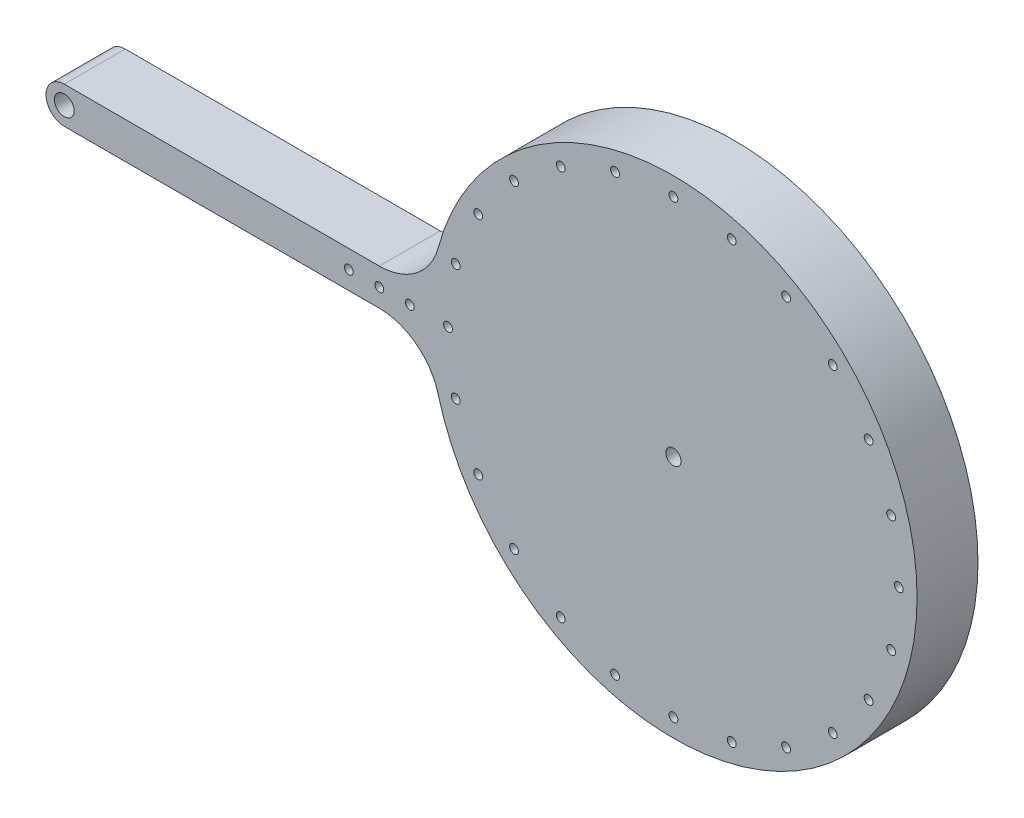
from build123d import *

# Parameters (mm, degrees)
SKETCH1_R           = 1.45
SKETCH1_R_2         = 1.450000001
SKETCH1_R_3         = 3.250000001
SKETCH1_R_4         = 2.5
BOSS_EXTRUDE2_DEPTH = 20


with BuildPart() as part:
    # Sketch1 → Boss-Extrude2 (new body)
    with BuildSketch(Plane.XY):
        with BuildLine():
            Line((-155.352886895, 10.211716756), (-51.913748531, 10.211716756))
            ThreePointArc((-51.913748531, 10.211716756), (-39.74822347, 6.086224622), (-32.601576204, -4.588283244))
            ThreePointArc((-32.601576204, -4.588283244), (53.610301025, -63.284580406), (124.587919611, 13.13479368))
            ThreePointArc((124.587919611, 13.13479368), (56.661218885, 95.304455124), (-32.601576204, 37.011716756))
            ThreePointArc((-32.601576204, 37.011716756), (-39.74822347, 26.33720889), (-51.913748531, 22.211716756))
            Line((-51.913748531, 22.211716756), (-155.352886895, 22.211716756))
            ThreePointArc((-155.352886895, 22.211716756), (-161.352886895, 16.211716756), (-155.352886895, 10.211716756))
        make_face()
        with Locations((-19.438766773, -20.788283244)):
            Circle(SKETCH1_R, mode=Mode.SUBTRACT)
        with Locations((-26.831398039, -2.940892579)):
            Circle(SKETCH1_R_2, mode=Mode.SUBTRACT)
        with Locations((-155.352886895, 16.211716756)):
            Circle(SKETCH1_R_3, mode=Mode.SUBTRACT)
        with Locations((-26.831398039, 35.364326096)):
            Circle(SKETCH1_R_2, mode=Mode.SUBTRACT)
        with Locations((-19.438766774, 53.211716759)):
            Circle(SKETCH1_R_2, mode=Mode.SUBTRACT)
        with Locations((-29.352886893, 16.211716758)):
            Circle(SKETCH1_R_2, mode=Mode.SUBTRACT)
        with Locations((-51.913748531, 16.211716758)):
            Circle(SKETCH1_R, mode=Mode.SUBTRACT)
        with Locations((-41.913748531, 16.211716758)):
            Circle(SKETCH1_R, mode=Mode.SUBTRACT)
        with Locations((-61.913748531, 16.211716758)):
            Circle(SKETCH1_R, mode=Mode.SUBTRACT)
        with Locations((116.125624253, -2.940892579)):
            Circle(SKETCH1_R_2, mode=Mode.SUBTRACT)
        with Locations((108.732992988, -20.788283242)):
            Circle(SKETCH1_R_2, mode=Mode.SUBTRACT)
        with Locations((96.973014915, -36.114185049)):
            Circle(SKETCH1_R_2, mode=Mode.SUBTRACT)
        with Locations((81.647113106, -47.874163121)):
            Circle(SKETCH1_R_2, mode=Mode.SUBTRACT)
        with Locations((63.799722443, -55.266794386)):
            Circle(SKETCH1_R_2, mode=Mode.SUBTRACT)
        with Locations((44.647113106, -57.788283242)):
            Circle(SKETCH1_R_2, mode=Mode.SUBTRACT)
        with Locations((25.494503768, -55.266794386)):
            Circle(SKETCH1_R_2, mode=Mode.SUBTRACT)
        with Locations((7.647113108, -47.874163121)):
            Circle(SKETCH1_R_2, mode=Mode.SUBTRACT)
        with Locations((-7.678788702, -36.114185049)):
            Circle(SKETCH1_R_2, mode=Mode.SUBTRACT)
        with Locations((44.647113106, 16.211716756)):
            Circle(SKETCH1_R_4, mode=Mode.SUBTRACT)
        with Locations((-7.678788702, 68.537618566)):
            Circle(SKETCH1_R_2, mode=Mode.SUBTRACT)
        with Locations((7.647113108, 80.297596638)):
            Circle(SKETCH1_R_2, mode=Mode.SUBTRACT)
        with Locations((25.494503768, 87.690227903)):
            Circle(SKETCH1_R_2, mode=Mode.SUBTRACT)
        with Locations((44.647113106, 90.211716759)):
            Circle(SKETCH1_R_2, mode=Mode.SUBTRACT)
        with Locations((63.799722443, 87.690227903)):
            Circle(SKETCH1_R_2, mode=Mode.SUBTRACT)
        with Locations((81.647113106, 80.297596638)):
            Circle(SKETCH1_R_2, mode=Mode.SUBTRACT)
        with Locations((96.973014915, 68.537618566)):
            Circle(SKETCH1_R_2, mode=Mode.SUBTRACT)
        with Locations((108.732992988, 53.211716759)):
            Circle(SKETCH1_R_2, mode=Mode.SUBTRACT)
        with Locations((116.125624253, 35.364326096)):
            Circle(SKETCH1_R_2, mode=Mode.SUBTRACT)
        with Locations((118.647113104, 16.211716758)):
            Circle(SKETCH1_R_2, mode=Mode.SUBTRACT)
    extrude(amount=BOSS_EXTRUDE2_DEPTH)


solid = part.part
